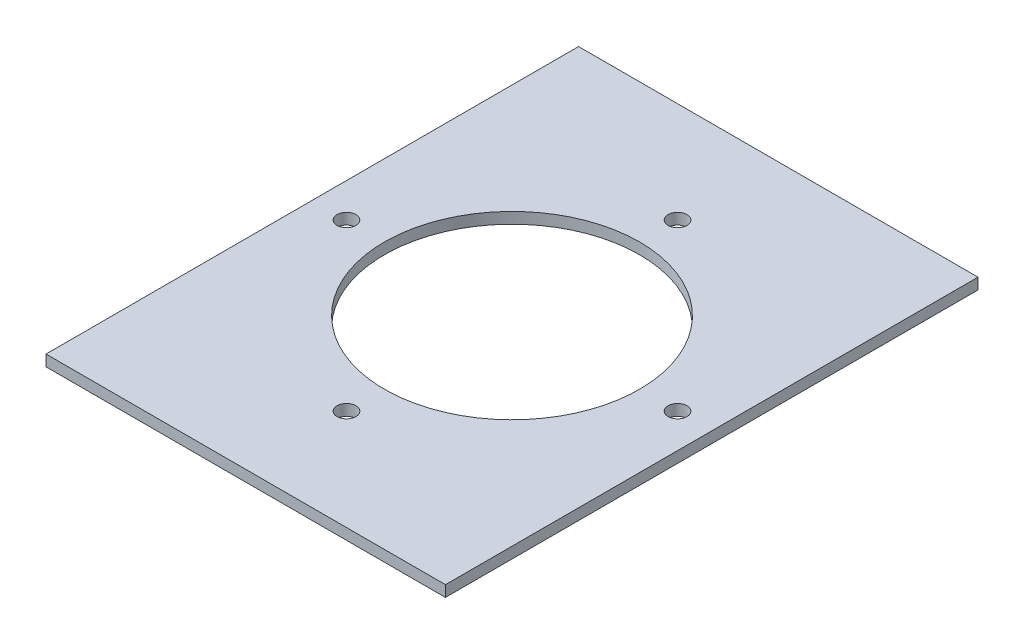
from build123d import *

# Parameters (mm, degrees)
SZKIC1_W                    = 180
SZKIC1_H                    = 240
DODANIE_WYCI_GNI_CIE1_DEPTH = 5
SZKIC2_R                    = 57.5
SZKIC2_R_2                  = 4.25
WYTNIJ_WYCI_GNI_CIE1_DEPTH  = 43
SZYK_KO_OWY1_COUNT          = 4


with BuildPart() as part:
    # Szkic1 → Dodanie-wyciągnięcie1 (new body)
    with BuildSketch(Plane(origin=(0, 0, 0), x_dir=(1, 0, 0), z_dir=(0, 1, 0))):
        Rectangle(SZKIC1_W, SZKIC1_H)
    extrude(amount=DODANIE_WYCI_GNI_CIE1_DEPTH)

    # Szkic2 → Wytnij-wyciągnięcie1 (cut)
    with BuildSketch(Plane(origin=(0, 0, 0), x_dir=(1, 0, 0), z_dir=(0, 1, 0))):
        Circle(SZKIC2_R)
        with Locations((0, 74.6)):
            Circle(SZKIC2_R_2)
    wytnij_wyci_gni_cie1 = extrude(amount=WYTNIJ_WYCI_GNI_CIE1_DEPTH, mode=Mode.SUBTRACT)

    # Szyk kołowy1: Wytnij-wyciągnięcie1 ×4 about axis
    szyk_ko_owy1_axis = Axis((0, 0, 0), (0, 1, 0))
    for i in range(1, SZYK_KO_OWY1_COUNT):
        add(wytnij_wyci_gni_cie1.rotate(szyk_ko_owy1_axis, i * 360 / SZYK_KO_OWY1_COUNT), mode=Mode.SUBTRACT)


solid = part.part
